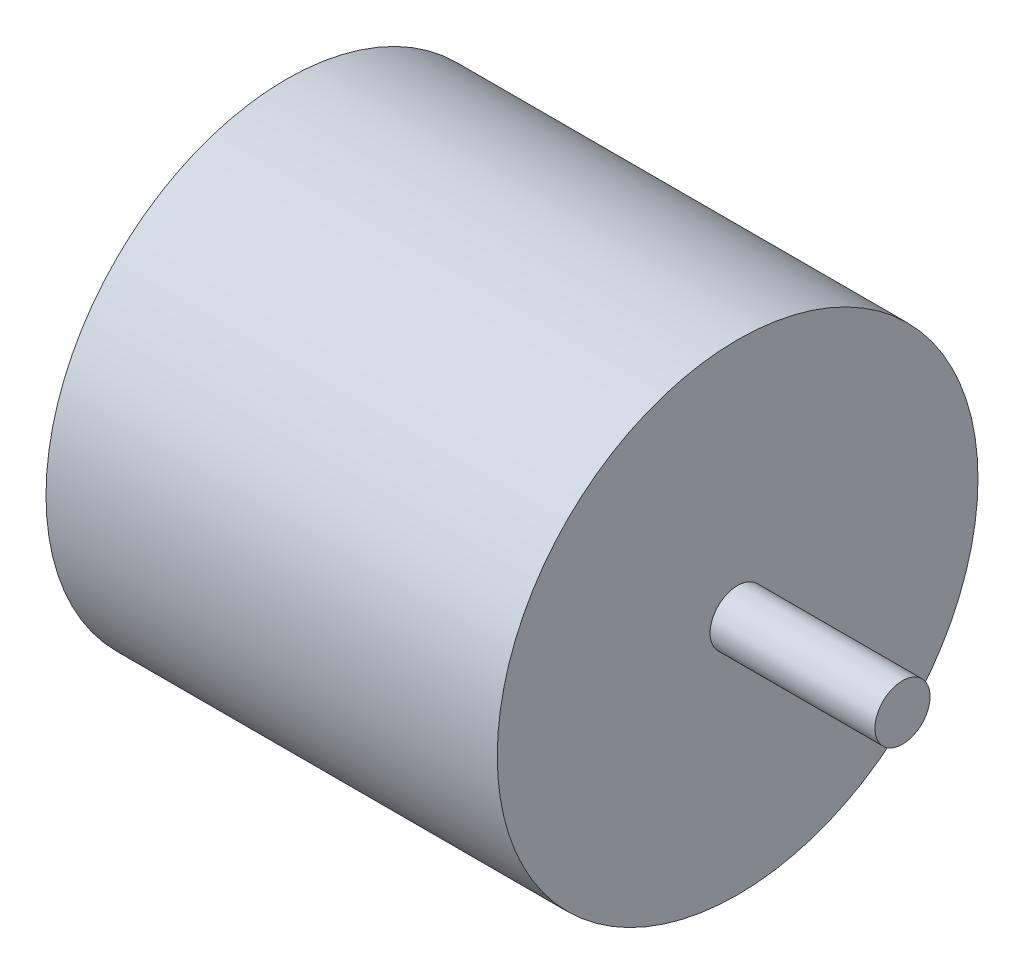
from build123d import *


with BuildPart() as part:
    # Sketch1 → Revolve1 (revolve)
    with BuildSketch(Plane.XY):
        Polygon((-14.5, 0), (-14.5, 1.5875), (-13, 1.5875), (-13, 13.85), (13, 13.85), (13, 1.5875), (22.5, 1.5875), (22.5, 0), align=None)
    revolve(axis=Axis((-313.759242266, 0, 0), (1, 0, 0)))


solid = part.part
